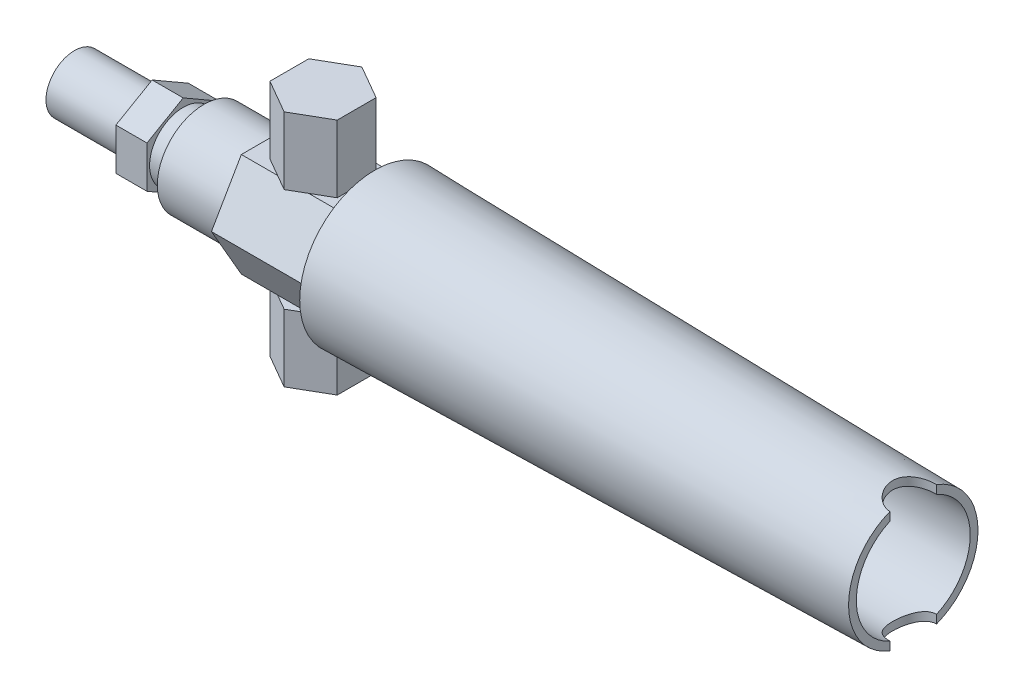
from build123d import *

# Parameters (mm, degrees)
BOSS_EXTRUDE1_DEPTH = 6
BOSS_EXTRUDE2_DEPTH = 20
SKETCH4_RX          = 4.5
SKETCH4_RY          = 4
CUT_EXTRUDE1_DEPTH  = 15
SKETCH5_R           = 11
CUT_EXTRUDE2_DEPTH  = 30
BOSS_EXTRUDE3_DEPTH = 13


with BuildPart() as part:
    # Sketch1 → Revolve1 (revolve)
    with BuildSketch(Plane.XY):
        Polygon((0, 0), (162, 0), (162, 12.5), (58, 14.5), (58, 9), (25, 9), (25, 6.5), (15, 6.5), (15, 5.5), (0, 5.5), align=None)
    revolve(axis=Axis((0, 0, 0), (1, 0, 0)))

    # Sketch2 → Boss-Extrude1 (add)
    with BuildSketch(Plane.ZY.offset(-15)):
        Polygon((0, 8.082903769), (-7, 4.041451884), (-7, -4.041451884), (0, -8.082903769), (7, -4.041451884), (7, 4.041451884), align=None)
    extrude(amount=-BOSS_EXTRUDE1_DEPTH)

    # Sketch3 → Boss-Extrude2 (add)
    with BuildSketch(Plane.ZY.offset(-58)):
        Polygon((5.773502692, 10), (-5.773502692, 10), (-11.547005384, 0), (-5.773502692, -10), (5.773502692, -10), (11.547005384, 0), align=None)
    extrude(amount=BOSS_EXTRUDE2_DEPTH)

    # Sketch4 → Cut-Extrude1 (cut, symmetric)
    with BuildSketch(Plane(origin=(0, 0, 0), x_dir=(1, 0, 0), z_dir=(0, 1, 0))):
        with Locations(Location((162, 0), (0, 0, 90))):
            Ellipse(SKETCH4_RX, SKETCH4_RY)
    extrude(amount=CUT_EXTRUDE1_DEPTH, both=True, mode=Mode.SUBTRACT)

    # Sketch5 → Cut-Extrude2 (cut)
    with BuildSketch(Plane(origin=(162, 0, 0), x_dir=(0, 0, -1), z_dir=(1, 0, 0))):
        Circle(SKETCH5_R)
    extrude(amount=-CUT_EXTRUDE2_DEPTH, mode=Mode.SUBTRACT)

    # Sketch6 → Boss-Extrude3 (add)
    with BuildSketch(Plane.XZ.offset(-10)):
        Polygon((48, 7.505553499), (41.5, 3.75277675), (41.5, -3.75277675), (48, -7.505553499), (54.5, -3.75277675), (54.5, 3.75277675), align=None)
    boss_extrude3 = extrude(amount=-BOSS_EXTRUDE3_DEPTH)

    # Mirror1: Boss-Extrude3 across plane
    add(boss_extrude3.mirror(Plane.ZX))


solid = part.part
